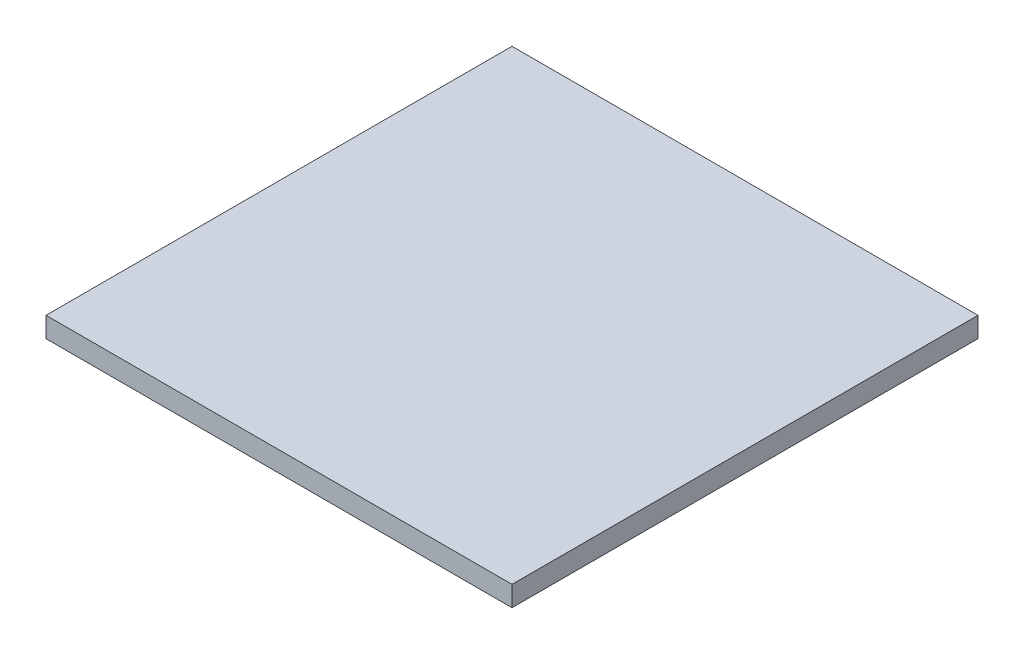
from build123d import *

# Parameters (mm, degrees)
SKETCH1_W           = 292.1
SKETCH1_H           = 292.1
BOSS_EXTRUDE1_DEPTH = 12.7


with BuildPart() as part:
    # Sketch1 → Boss-Extrude1 (new body)
    with BuildSketch(Plane(origin=(0, 0, 0), x_dir=(1, 0, 0), z_dir=(0, 1, 0))):
        Rectangle(SKETCH1_W, SKETCH1_H)
    extrude(amount=BOSS_EXTRUDE1_DEPTH)


solid = part.part
